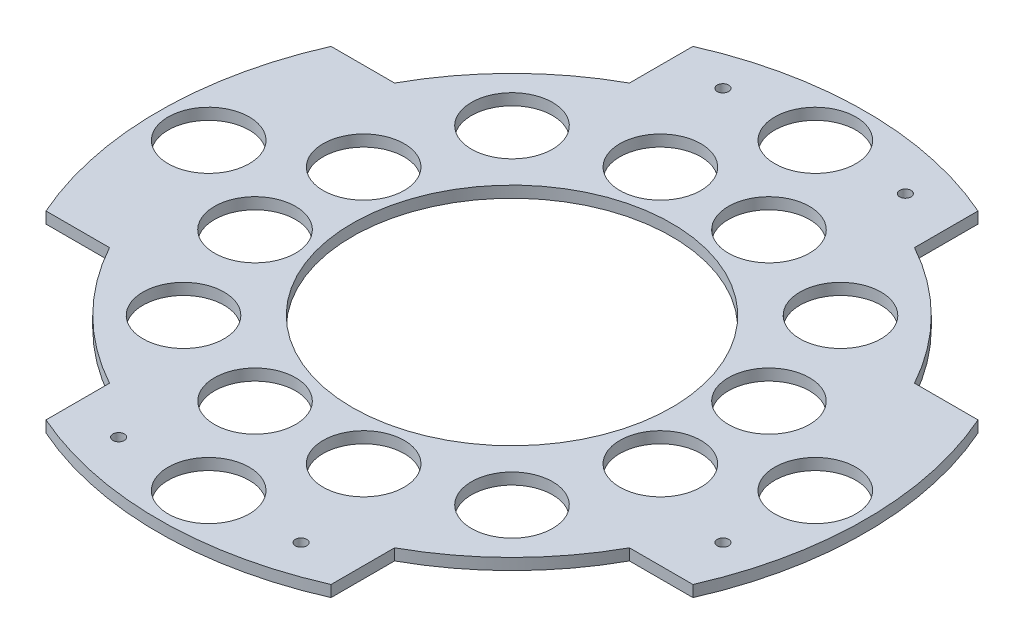
from build123d import *

# Parameters (mm, degrees)
SKETCH1_R           = 7
BOSS_EXTRUDE1_DEPTH = 0.5
SKETCH2_R           = 1.778
CUT_EXTRUDE2_DEPTH  = 1.5
SKETCH4_R           = 0.25
CUT_EXTRUDE3_DEPTH  = 1.5


with BuildPart() as part:
    # Sketch1 → Boss-Extrude1 (new body)
    with BuildSketch(Plane(origin=(0, 0, 0), x_dir=(1, 0, 0), z_dir=(0, 1, 0))):
        with BuildLine():
            Line((-6.25, 14.184057953), (-6.25, 11.399013115))
            ThreePointArc((-6.25, 11.399013115), (-9.192388155, 9.192388155), (-11.399013115, 6.25))
            Line((-11.399013115, 6.25), (-14.184057953, 6.25))
            ThreePointArc((-14.184057953, 6.25), (-15.5, 0), (-14.184057953, -6.25))
            Line((-14.184057953, -6.25), (-11.399013115, -6.25))
            ThreePointArc((-11.399013115, -6.25), (-9.192388155, -9.192388155), (-6.25, -11.399013115))
            Line((-6.25, -11.399013115), (-6.25, -14.184057953))
            ThreePointArc((-6.25, -14.184057953), (0, -15.5), (6.25, -14.184057953))
            Line((6.25, -14.184057953), (6.25, -11.399013115))
            ThreePointArc((6.25, -11.399013115), (9.192388155, -9.192388155), (11.399013115, -6.25))
            Line((11.399013115, -6.25), (14.184057953, -6.25))
            ThreePointArc((14.184057953, -6.25), (15.5, 0), (14.184057953, 6.25))
            Line((14.184057953, 6.25), (11.399013115, 6.25))
            ThreePointArc((11.399013115, 6.25), (9.192388155, 9.192388155), (6.25, 11.399013115))
            Line((6.25, 11.399013115), (6.25, 14.184057953))
            ThreePointArc((6.25, 14.184057953), (0, 15.5), (-6.25, 14.184057953))
        make_face()
        Circle(SKETCH1_R, mode=Mode.SUBTRACT)
    extrude(amount=BOSS_EXTRUDE1_DEPTH)

    # Sketch2 → Cut-Extrude2 (cut, through all)
    with BuildSketch(Plane(origin=(0, 0.5, 0), x_dir=(1, 0, 0), z_dir=(0, 1, 0))):
        with Locations((0, 13.3)):
            Circle(SKETCH2_R)
        with Locations((-2.381135215, 8.886517602)):
            Circle(SKETCH2_R)
        with Locations((-13.3, 0)):
            Circle(SKETCH2_R)
        with Locations((-8.886517602, 2.381135215)):
            Circle(SKETCH2_R)
        with Locations((-7.201882566, 7.201882566)):
            Circle(SKETCH2_R)
        with Locations((0, -13.3)):
            Circle(SKETCH2_R)
        with Locations((-2.381135215, -8.886517602)):
            Circle(SKETCH2_R)
        with Locations((-7.201882566, -7.201882566)):
            Circle(SKETCH2_R)
        with Locations((-8.886517602, -2.381135215)):
            Circle(SKETCH2_R)
        with Locations((2.381135215, 8.886517602)):
            Circle(SKETCH2_R)
        with Locations((7.201882566, 7.201882566)):
            Circle(SKETCH2_R)
        with Locations((8.886517602, 2.381135215)):
            Circle(SKETCH2_R)
        with Locations((13.3, 0)):
            Circle(SKETCH2_R)
        with Locations((8.886517602, -2.381135215)):
            Circle(SKETCH2_R)
        with Locations((7.201882566, -7.201882566)):
            Circle(SKETCH2_R)
        with Locations((2.381135215, -8.886517602)):
            Circle(SKETCH2_R)
    extrude(amount=-CUT_EXTRUDE2_DEPTH, mode=Mode.SUBTRACT)

    # Sketch4 → Cut-Extrude3 (cut, through all)
    with BuildSketch(Plane(origin=(0, 0.5, 0), x_dir=(1, 0, 0), z_dir=(0, 1, 0))):
        with Locations((-4, 13.25)):
            Circle(SKETCH4_R)
        with Locations((13.25, -4)):
            Circle(SKETCH4_R)
        with Locations((4, -13.25)):
            Circle(SKETCH4_R)
        with Locations((-4, -13.25)):
            Circle(SKETCH4_R)
        with Locations((4, 13.25)):
            Circle(SKETCH4_R)
    extrude(amount=-CUT_EXTRUDE3_DEPTH, mode=Mode.SUBTRACT)


solid = part.part
